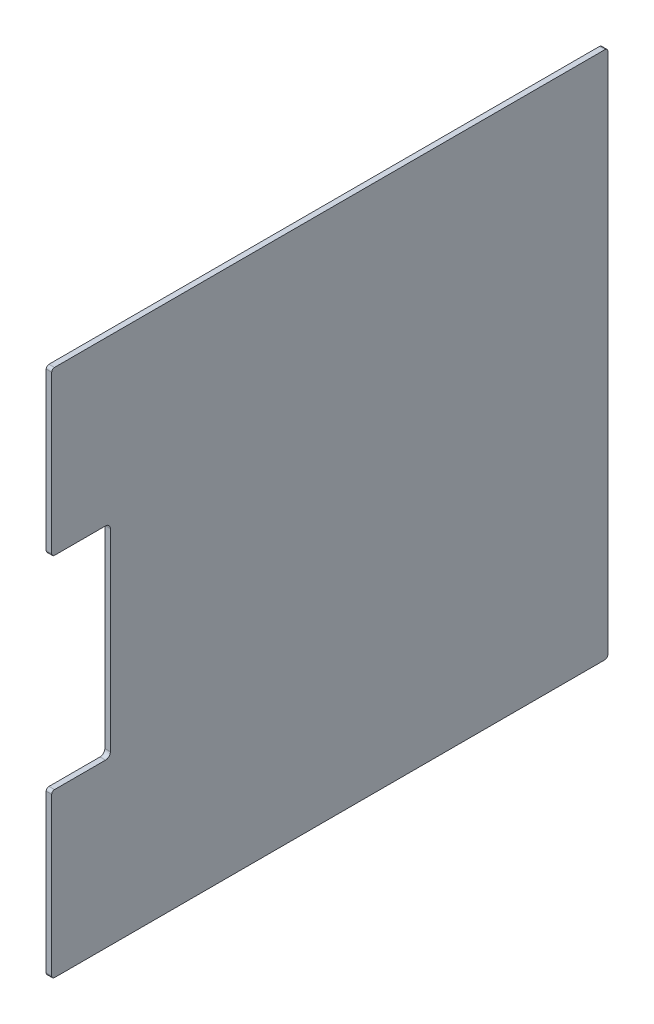
from build123d import *

# Parameters (mm, degrees)
BOSS_EXTRUDE1_DEPTH = 4


with BuildPart() as part:
    # Sketch1 → Boss-Extrude1 (new body)
    with BuildSketch(Plane(origin=(-22.493180964, 0, 0), x_dir=(0, 0, -1), z_dir=(1, 0, 0))):
        with BuildLine():
            Line((41.499999434, -352.52261402), (41.499999434, 26.477385891))
            ThreePointArc((41.499999434, 26.477385891), (40.914212996, 27.891599453), (39.499999434, 28.477385891))
            Line((39.499999434, 28.477385891), (-359.500000477, 28.477385891))
            ThreePointArc((-359.500000477, 28.477385891), (-360.914214039, 27.891599453), (-361.500000477, 26.477385891))
            Line((-361.500000477, 26.477385891), (-361.500000477, -87.499667694))
            ThreePointArc((-361.500000477, -87.499667694), (-360.914214039, -88.913881256), (-359.500000477, -89.499667694))
            Line((-359.500000477, -89.499667694), (-322.5, -89.499667694))
            ThreePointArc((-322.5, -89.499667694), (-320.025126266, -90.524793959), (-319, -92.999667694))
            Line((-319, -92.999667694), (-319, -232.999667694))
            ThreePointArc((-319, -232.999667694), (-320.025126266, -235.474541428), (-322.5, -236.499667694))
            Line((-322.5, -236.499667694), (-359.500000477, -236.499667694))
            ThreePointArc((-359.500000477, -236.499667694), (-360.914214039, -237.085454131), (-361.500000477, -238.499667694))
            Line((-361.500000477, -238.499667694), (-361.500000477, -352.52261402))
            ThreePointArc((-361.500000477, -352.52261402), (-360.914214039, -353.936827582), (-359.500000477, -354.52261402))
            Line((-359.500000477, -354.52261402), (39.499999434, -354.52261402))
            ThreePointArc((39.499999434, -354.52261402), (40.914212996, -353.936827582), (41.499999434, -352.52261402))
        make_face()
    extrude(amount=-BOSS_EXTRUDE1_DEPTH)


solid = part.part
